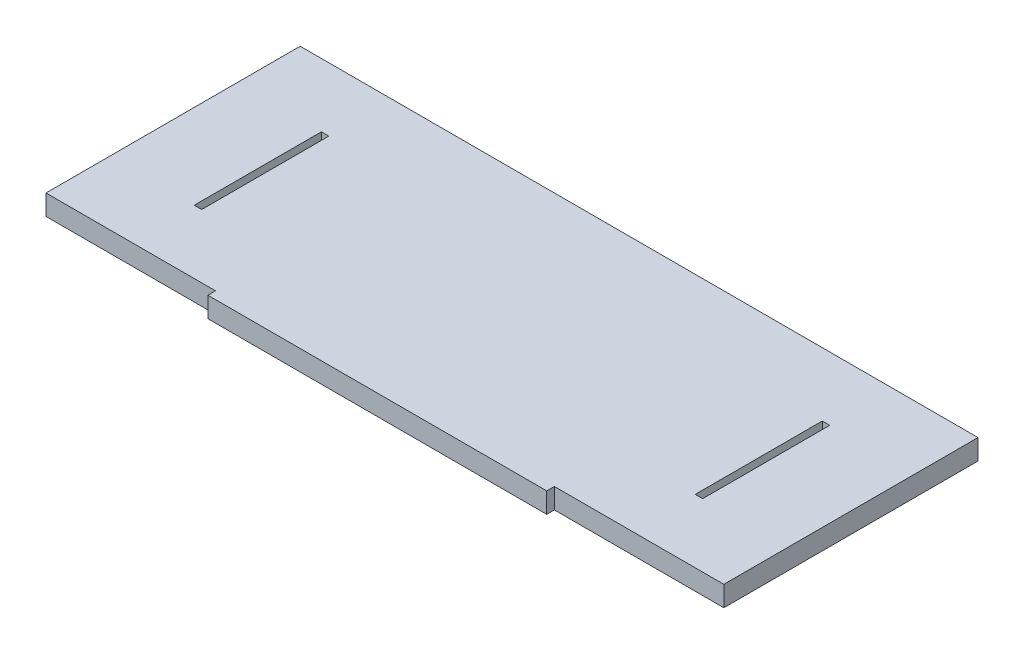
from build123d import *

# Parameters (mm, degrees)
SKETCH1_W           = 200
SKETCH1_H           = 4.5
BOSS_EXTRUDE1_DEPTH = 12
SKETCH3_W           = 4.4
SKETCH3_H           = 75
CUT_EXTRUDE1_DEPTH  = 12


with BuildPart() as part:
    # Sketch1 → Boss-Extrude1 (new body)
    with BuildSketch(Plane(origin=(0, 0, 0), x_dir=(1, 0, 0), z_dir=(0, 1, 0))):
        Polygon((200, 75), (-200, 75), (-200, -75), (-100, -75), (-100, -70.5), (100, -70.5), (100, -75), (200, -75), align=None)
        with Locations((0, -77.25)):
            Rectangle(SKETCH1_W, SKETCH1_H)
        with Locations((0, -72.75)):
            Rectangle(SKETCH1_W, SKETCH1_H)
    extrude(amount=BOSS_EXTRUDE1_DEPTH)

    # Sketch3 → Cut-Extrude1 (cut)
    with BuildSketch(Plane(origin=(0, 12, 0), x_dir=(1, 0, 0), z_dir=(0, 1, 0))):
        with Locations((-147.8, 0)):
            Rectangle(SKETCH3_W, SKETCH3_H)
    cut_extrude1 = extrude(amount=-CUT_EXTRUDE1_DEPTH, mode=Mode.SUBTRACT)

    # Mirror1: Cut-Extrude1 across plane
    add(cut_extrude1.mirror(Plane(origin=(0, 0, 0), x_dir=(0, 0, 1), z_dir=(1, 0, 0))), mode=Mode.SUBTRACT)


solid = part.part
